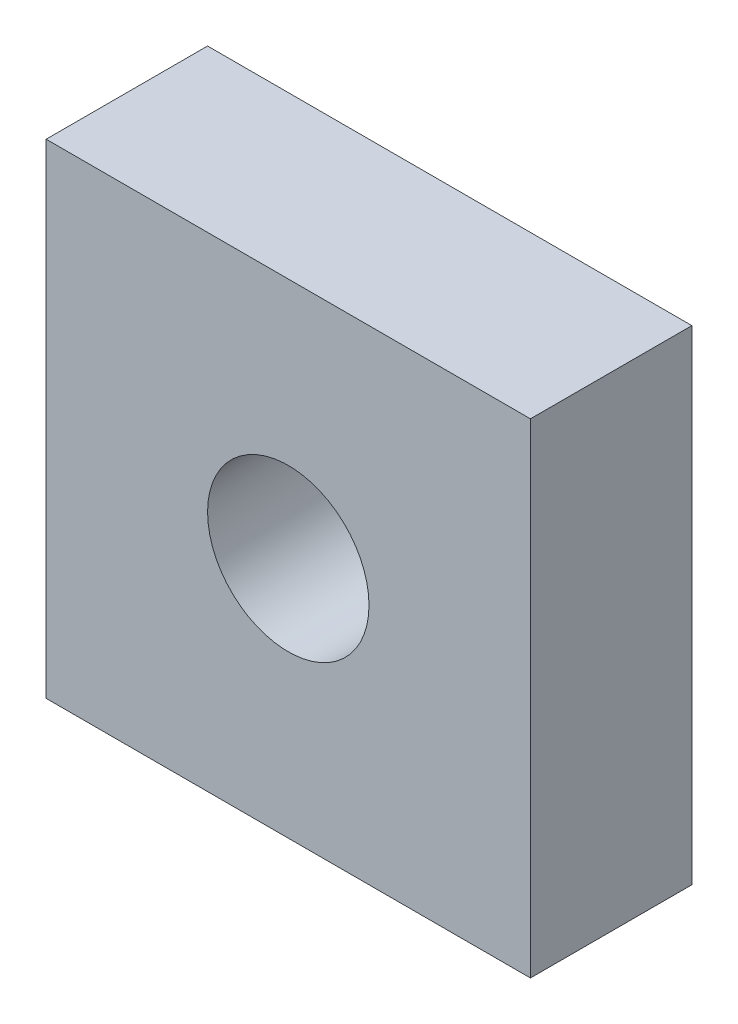
from build123d import *

# Parameters (mm, degrees)
SKETCH1_W           = 30
SKETCH1_H           = 30
SKETCH1_R           = 5
BOSS_EXTRUDE1_DEPTH = 10


with BuildPart() as part:
    # Sketch1 → Boss-Extrude1 (new body)
    with BuildSketch(Plane.XY):
        with Locations((15, 15)):
            Rectangle(SKETCH1_W, SKETCH1_H)
        with Locations((15, 15)):
            Circle(SKETCH1_R, mode=Mode.SUBTRACT)
    extrude(amount=BOSS_EXTRUDE1_DEPTH)


solid = part.part
